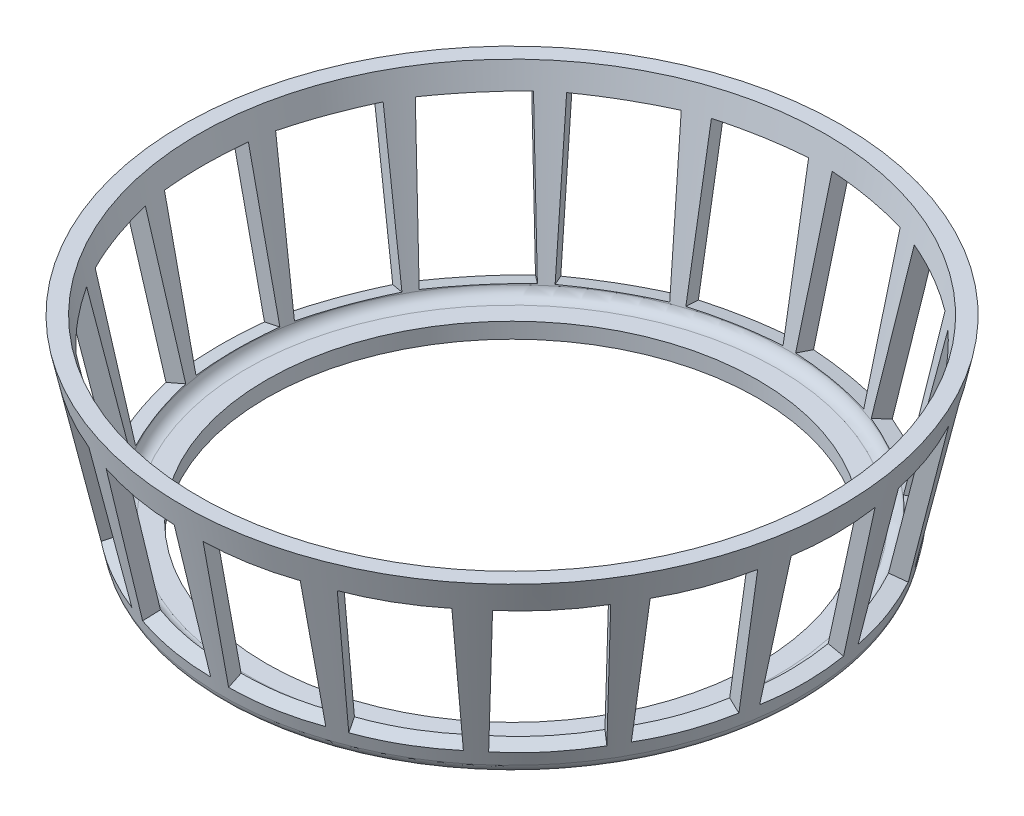
from build123d import *

# Parameters (mm, degrees)
SKETCH3_W          = 12.35
SKETCH3_H          = 7
CUT_EXTRUDE1_DEPTH = 10
CIRPATTERN1_COUNT  = 18


with BuildPart() as part:
    # Sketch1 → Revolve3 (revolve)
    with BuildSketch(Plane.XY):
        with BuildLine():
            Line((-24.170190138, 0.789195982), (-27.5, 16.23))
            Line((-27.5, 16.23), (-26.17011529, 16.23))
            Line((-26.17011529, 16.23), (-23.120650468, 2.089195982))
            ThreePointArc((-23.120650468, 2.089195982), (-22.771292475, 1.521924163), (-22.143122123, 1.3))
            Line((-22.143122123, 1.3), (-20.5, 1.3))
            Line((-20.5, 1.3), (-20.5, 0))
            Line((-20.5, 0), (-23.192661792, 0))
            ThreePointArc((-23.192661792, 0), (-23.820832144, 0.221924163), (-24.170190138, 0.789195982))
        make_face()
    revolve(axis=Axis((0, 0, 0), (0, 1, 0)))

    # Sketch3 → Cut-Extrude1 (cut)
    with BuildSketch(Plane(origin=(22.933479986, -4.945605665, 0), x_dir=(-0.210804018, -0.977528345, 0), z_dir=(0.977528345, -0.210804018, 0))):
        with Locations((-13.137395536, 0)):
            Rectangle(SKETCH3_W, SKETCH3_H)
    cut_extrude1 = extrude(amount=-CUT_EXTRUDE1_DEPTH, mode=Mode.SUBTRACT)

    # CirPattern1: Cut-Extrude1 ×18 about axis
    cirpattern1_axis = Axis((0, 0, 0), (0, 1, 0))
    for i in range(1, CIRPATTERN1_COUNT):
        add(cut_extrude1.rotate(cirpattern1_axis, i * 360 / CIRPATTERN1_COUNT), mode=Mode.SUBTRACT)


solid = part.part
